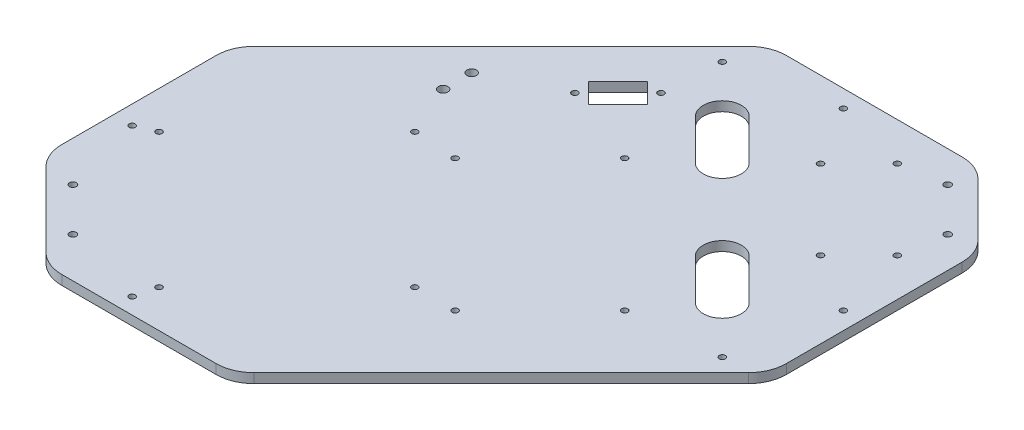
from build123d import *

# Parameters (mm, degrees)
SKETCH1_R           = 1.8
SKETCH1_R_2         = 1.6
SKETCH1_R_3         = 2.5
BOSS_EXTRUDE1_DEPTH = 5


with BuildPart() as part:
    # Sketch1 → Boss-Extrude1 (new body)
    with BuildSketch(Plane(origin=(0, 0, 0), x_dir=(1, 0, 0), z_dir=(0, 1, 0))):
        with BuildLine():
            Line((-40.201849804, 94.840698314), (89.589997394, 224.632545513))
            ThreePointArc((89.589997394, 224.632545513), (96.07846437, 228.968000539), (103.732133018, 230.490409889))
            Line((103.732133018, 230.490409889), (196.158539889, 230.490409889))
            ThreePointArc((196.158539889, 230.490409889), (203.812208536, 228.968000539), (210.300675513, 224.632545513))
            Line((210.300675513, 224.632545513), (238.082421443, 196.850799582))
            ThreePointArc((238.082421443, 196.850799582), (242.41787647, 190.362332606), (243.940285819, 182.708663958))
            Line((243.940285819, 182.708663958), (243.940285819, 90.282257087))
            ThreePointArc((243.940285819, 90.282257087), (242.41787647, 82.62858844), (238.082421443, 76.140121463))
            Line((238.082421443, 76.140121463), (108.290574245, -53.651725735))
            ThreePointArc((108.290574245, -53.651725735), (101.802107268, -57.987180761), (94.148438621, -59.509590111))
            Line((94.148438621, -59.509590111), (13.035740249, -59.509590111))
            ThreePointArc((13.035740249, -59.509590111), (5.382071602, -57.987180761), (-1.106395375, -53.651725735))
            Line((-1.106395375, -53.651725735), (-40.201849804, -14.556271305))
            ThreePointArc((-40.201849804, -14.556271305), (-44.537304831, -8.067804329), (-46.059714181, -0.414135682))
            Line((-46.059714181, -0.414135682), (-46.059714181, 80.698562691))
            ThreePointArc((-46.059714181, 80.698562691), (-44.537304831, 88.352231338), (-40.201849804, 94.840698314))
        make_face()
        with Locations((-24.896763277, -15.719222209)):
            Circle(SKETCH1_R, mode=Mode.SUBTRACT)
        with Locations((-2.269346279, -38.346639207)):
            Circle(SKETCH1_R, mode=Mode.SUBTRACT)
        with Locations((204.912940609, 214.090481676)):
            Circle(SKETCH1_R, mode=Mode.SUBTRACT)
        with Locations((227.540357607, 191.463064678)):
            Circle(SKETCH1_R, mode=Mode.SUBTRACT)
        with Locations((-26.310976839, 30.949825349)):
            Circle(SKETCH1_R_2, mode=Mode.SUBTRACT)
        with Locations((44.39970128, -39.76085277)):
            Circle(SKETCH1_R_2, mode=Mode.SUBTRACT)
        with Locations((111.574845492, 27.414291443)):
            Circle(SKETCH1_R_2, mode=Mode.SUBTRACT)
        with Locations((40.864167374, 98.124969562)):
            Circle(SKETCH1_R_2, mode=Mode.SUBTRACT)
        with Locations((-36.197611828, 26.694324714)):
            Circle(SKETCH1_R_2, mode=Mode.SUBTRACT)
        with Locations((41.584134103, -51.087421217)):
            Circle(SKETCH1_R_2, mode=Mode.SUBTRACT)
        with Locations((63.491584372, 96.710755999)):
            Circle(SKETCH1_R_2, mode=Mode.SUBTRACT)
        with Locations((132.788048928, 27.414291443)):
            Circle(SKETCH1_R_2, mode=Mode.SUBTRACT)
        with Locations((177.335776143, 71.962018658)):
            Circle(SKETCH1_R_2, mode=Mode.SUBTRACT)
        with Locations((108.039311586, 141.258483214)):
            Circle(SKETCH1_R_2, mode=Mode.SUBTRACT)
        with Locations((161.966151733, 190.235575893)):
            Circle(SKETCH1_R_2, mode=Mode.SUBTRACT)
        with Locations((203.685451823, 148.516275803)):
            Circle(SKETCH1_R_2, mode=Mode.SUBTRACT)
        with Locations((223.837995087, 168.668819067)):
            Circle(SKETCH1_R_2, mode=Mode.SUBTRACT)
        with Locations((182.118694997, 210.388119157)):
            Circle(SKETCH1_R_2, mode=Mode.SUBTRACT)
        with Locations((89.841260052, 210.741672547)):
            Circle(SKETCH1_R_2, mode=Mode.SUBTRACT)
        with Locations((224.191548478, 76.391384122)):
            Circle(SKETCH1_R_2, mode=Mode.SUBTRACT)
        with Locations((65.246851643, 157.862992891)):
            Circle(SKETCH1_R_2, mode=Mode.SUBTRACT)
        with Locations((87.874268641, 180.490409889)):
            Circle(SKETCH1_R_2, mode=Mode.SUBTRACT)
        with Locations((142.874268641, 221.348274265)):
            Circle(SKETCH1_R_2, mode=Mode.SUBTRACT)
        with Locations((234.798150196, 129.424392711)):
            Circle(SKETCH1_R_2, mode=Mode.SUBTRACT)
        with Locations((28.940285819, 139.941203378)):
            Circle(SKETCH1_R_3, mode=Mode.SUBTRACT)
        with Locations((28.940285819, 124.941203378)):
            Circle(SKETCH1_R_3, mode=Mode.SUBTRACT)
        with BuildLine():
            Line((121.661065206, 193.064003018), (142.874268641, 171.850799582))
            ThreePointArc((142.874268641, 171.850799582), (142.874268641, 157.708663958), (128.732133018, 157.708663958))
            Line((128.732133018, 157.708663958), (107.518929582, 178.921867394))
            ThreePointArc((107.518929582, 178.921867394), (107.518929582, 193.064003018), (121.661065206, 193.064003018))
        make_face(mode=Mode.SUBTRACT)
        with BuildLine():
            Line((185.300675513, 129.424392711), (206.513878948, 108.211189275))
            ThreePointArc((206.513878948, 108.211189275), (206.513878948, 94.069053651), (192.371743324, 94.069053651))
            Line((192.371743324, 94.069053651), (171.158539889, 115.282257087))
            ThreePointArc((171.158539889, 115.282257087), (171.158539889, 129.424392711), (185.300675513, 129.424392711))
        make_face(mode=Mode.SUBTRACT)
        Polygon((63.47908469, 166.701827656), (74.085686408, 156.095225938), (89.642035594, 171.651575124), (79.035433877, 182.258176842), align=None, mode=Mode.SUBTRACT)
    extrude(amount=BOSS_EXTRUDE1_DEPTH)


solid = part.part
